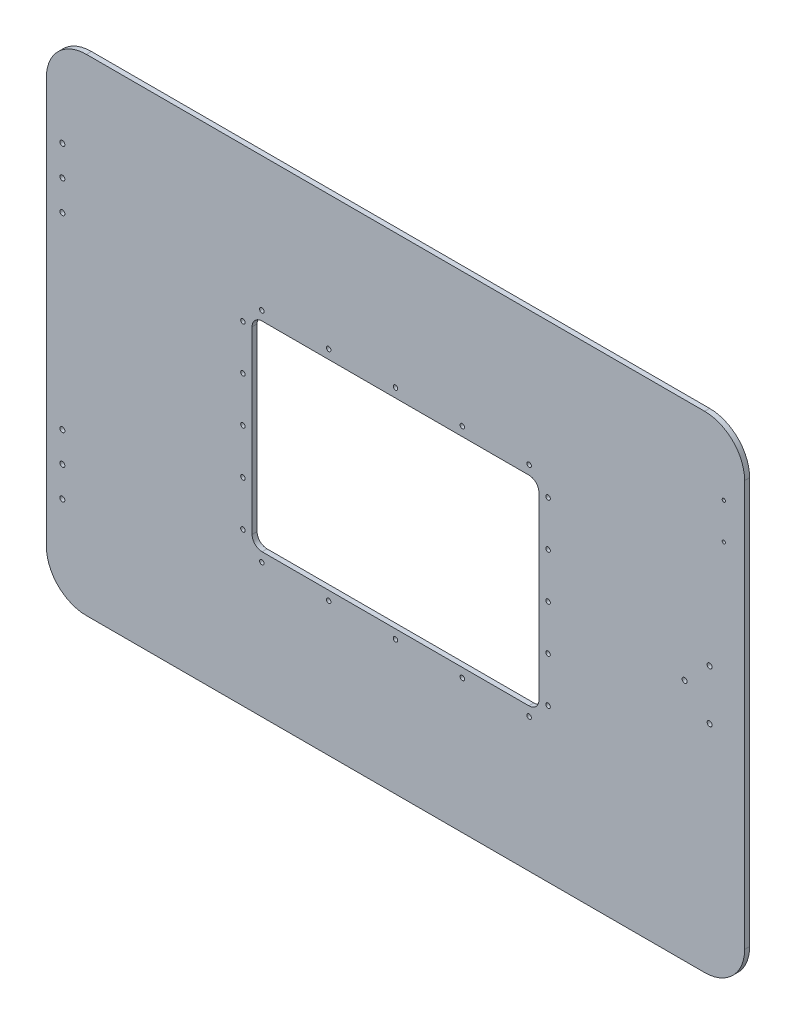
from build123d import *

# Parameters (mm, degrees)
SKETCH1_W            = 698
SKETCH1_H            = 485.9
BOSS_EXTRUDE1_DEPTH  = 5
FILLET1_R            = 40
M6_TAPPED_HOLE1_D    = 5
M6_TAPPED_HOLE2_D    = 5
M4_TAPPED_HOLE1_D    = 3.3
SKETCH8_W            = 286.7
SKETCH8_H            = 199.7
CUT_EXTRUDE1_DEPTH   = 6
FILLET2_R            = 10
M4_CLEARANCE_HOLE1_D = 4.5


with BuildPart() as part:
    # Sketch1 → Boss-Extrude1 (new body)
    with BuildSketch(Plane.XY):
        Rectangle(SKETCH1_W, SKETCH1_H)
    extrude(amount=BOSS_EXTRUDE1_DEPTH)

    # Fillet1
    fillet1_edges = [part.edges().sort_by_distance(p)[0] for p in [
        (-349, 242.95, 2.5),
        (349, 242.95, 2.5),
        (349, -242.95, 2.5),
        (-349, -242.95, 2.5),
    ]]
    fillet(fillet1_edges, radius=FILLET1_R)

    # M6 Tapped Hole1 (through all)
    with Locations(Plane.XY.offset(5)):
        with Locations((-333, 153.95), (-333, 123.95), (-333, 93.95)):
            m6_tapped_hole1 = Hole(M6_TAPPED_HOLE1_D / 2)

    # M6 Tapped Hole2 (through all)
    with Locations(Plane.XY.offset(5)):
        with Locations((314, 25), (289, 0), (314, -25)):
            Hole(M6_TAPPED_HOLE2_D / 2)

    # Mirror1: M6 Tapped Hole1 across plane
    add(m6_tapped_hole1.mirror(Plane.ZX), mode=Mode.SUBTRACT)

    # M4 Tapped Hole1 (through all)
    with Locations(Plane.XY.offset(5)):
        with Locations((328.180642757, 175.458967428), (328.180642757, 139.458967428)):
            Hole(M4_TAPPED_HOLE1_D / 2)

    # Sketch8 → Cut-Extrude1 (cut, through all)
    with BuildSketch(Plane.XY.offset(5)):
        Rectangle(SKETCH8_W, SKETCH8_H)
    extrude(amount=-CUT_EXTRUDE1_DEPTH, mode=Mode.SUBTRACT)

    # Fillet2
    fillet2_edges = [part.edges().sort_by_distance(p)[0] for p in [
        (143.35, -99.85, 2.5),
        (-143.35, -99.85, 2.5),
        (-143.35, 99.85, 2.5),
        (143.35, 99.85, 2.5),
    ]]
    fillet(fillet2_edges, radius=FILLET2_R)

    # M4 Clearance Hole1 (through all)
    with Locations(Plane.XY.offset(5)):
        with Locations((152.5, 90.1), (152.5, 45.05), (133.6, 109), (66.8, 109), (0, 109), (-66.8, 109), (-133.6, 109), (-152.5, 90.1), (-152.5, 45.05), (-152.5, 0), (-152.5, -45.05), (-152.5, -90.1), (-133.6, -109), (-66.8, -109), (0, -109), (66.8, -109), (133.6, -109), (152.5, -90.1), (152.5, -45.05), (152.5, 0)):
            Hole(M4_CLEARANCE_HOLE1_D / 2)


solid = part.part
